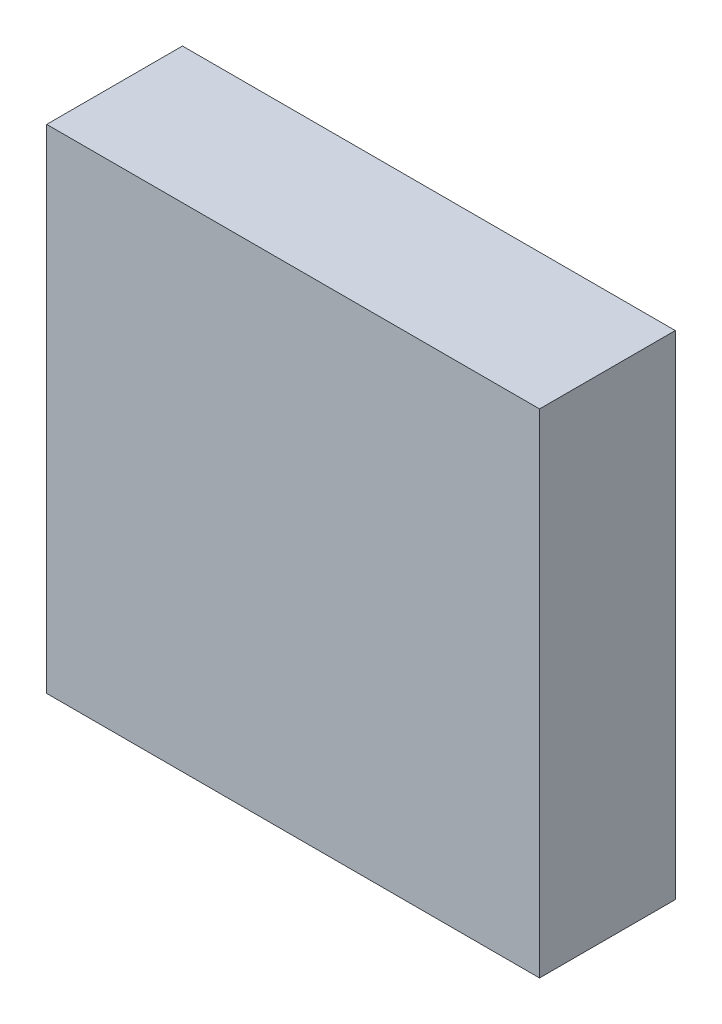
from build123d import *

# Parameters (mm, degrees)
SKETCH_1_W      = 83.5
SKETCH_1_H      = 83.5
SKETCH_1_W_2    = 77.5
SKETCH_1_H_2    = 77.5
EXTRUDE_1_DEPTH = 20
CHAMFER_1_SIZE  = 1.5
SKETCH_2_W      = 83.5
SKETCH_2_H      = 83.5
EXTRUDE_2_DEPTH = 3


with BuildPart() as part:
    # Эскиз1 → Бобышка-Вытянуть1 (new body)
    with BuildSketch(Plane.XY):
        with Locations((38.75, 38.75)):
            Rectangle(SKETCH_1_W, SKETCH_1_H)
        with Locations((38.75, 38.75)):
            Rectangle(SKETCH_1_W_2, SKETCH_1_H_2, mode=Mode.SUBTRACT)
    extrude(amount=EXTRUDE_1_DEPTH)

    # Фаска1
    chamfer_1_edges = [part.edges().sort_by_distance(p)[0] for p in [
        (0, 38.75, 0),
        (38.75, 0, 0),
        (77.5, 38.75, 0),
        (38.75, 77.5, 0),
    ]]
    chamfer(chamfer_1_edges, length=CHAMFER_1_SIZE)

    # Эскиз2 → Бобышка-Вытянуть2 (add)
    with BuildSketch(Plane.XY.offset(20)):
        with Locations((38.75, 38.75)):
            Rectangle(SKETCH_2_W, SKETCH_2_H)
    extrude(amount=EXTRUDE_2_DEPTH)


solid = part.part
